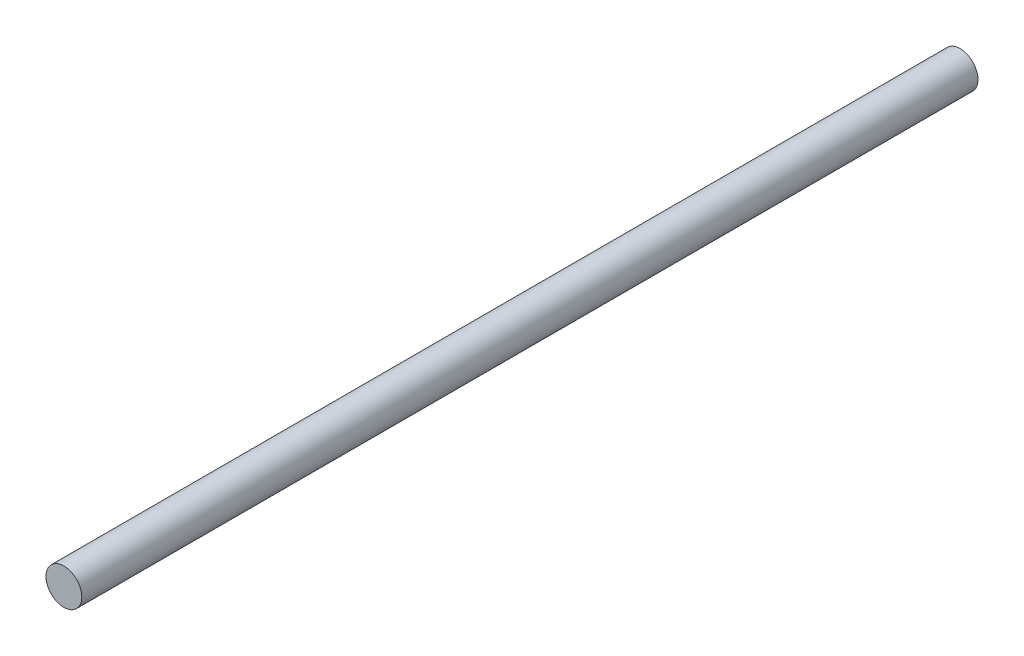
from build123d import *

# Parameters (mm, degrees)
IZIM1_R                     = 2
Y_KSEKLIK_EKSTR_ZYON1_DEPTH = 100


with BuildPart() as part:
    # Çizim1 → Yükseklik-Ekstrüzyon1 (new body)
    with BuildSketch(Plane.XY):
        Circle(IZIM1_R)
    extrude(amount=Y_KSEKLIK_EKSTR_ZYON1_DEPTH)


solid = part.part
